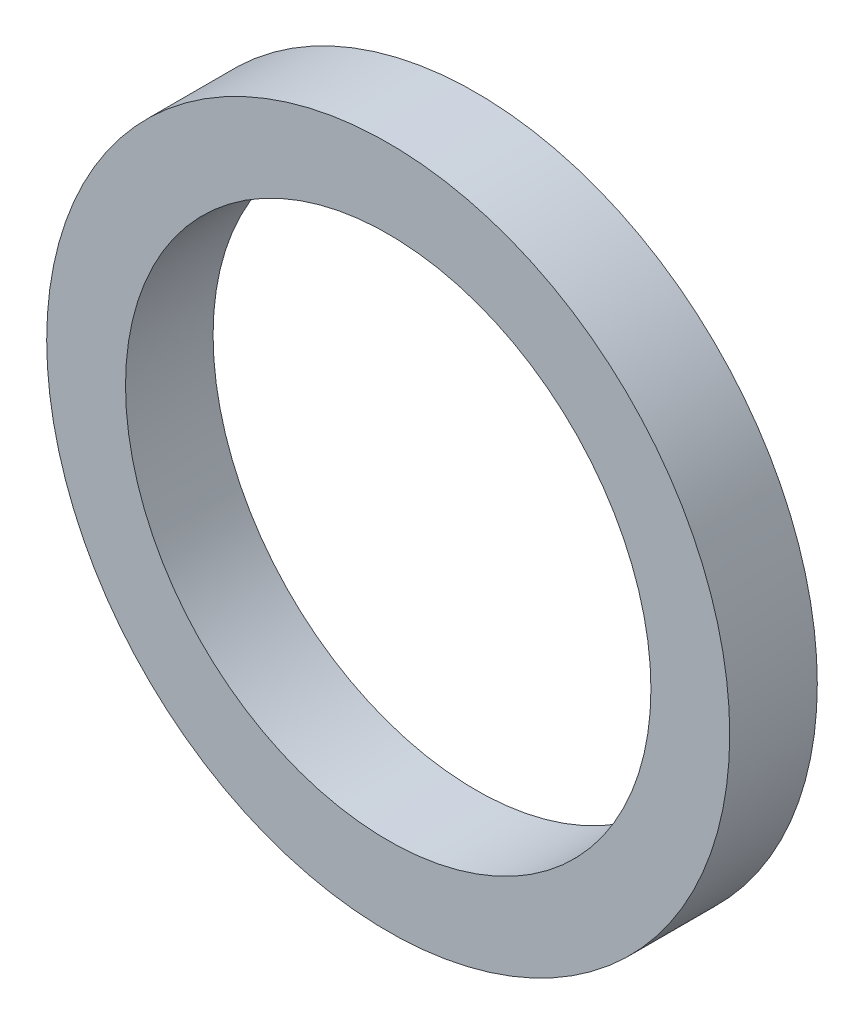
from build123d import *

# Parameters (mm, degrees)
SKETCH1_R           = 39
SKETCH1_R_2         = 30
BOSS_EXTRUDE1_DEPTH = 10


with BuildPart() as part:
    # Sketch1 → Boss-Extrude1 (new body)
    with BuildSketch(Plane.XY):
        Circle(SKETCH1_R)
        Circle(SKETCH1_R_2, mode=Mode.SUBTRACT)
    extrude(amount=BOSS_EXTRUDE1_DEPTH)


solid = part.part
